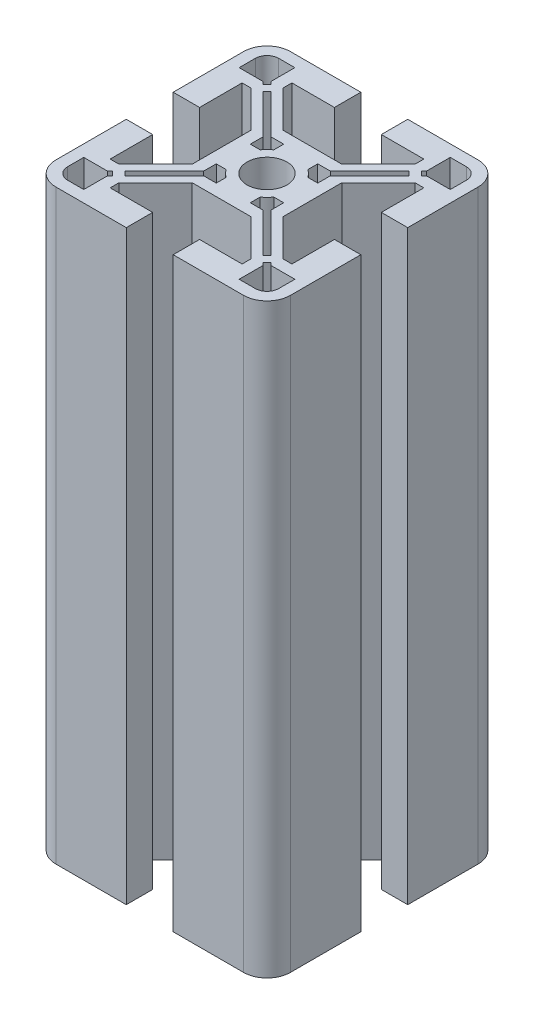
from build123d import *

# Parameters (mm, degrees)
BOSS_EXTRUDE1_DEPTH = 100


with BuildPart() as part:
    # Sketch1 → Boss-Extrude1 (new body)
    with BuildSketch(Plane(origin=(0, 0, 0), x_dir=(1, 0, 0), z_dir=(0, 1, 0))):
        with BuildLine():
            Line((-20, 4), (-20, 16))
            ThreePointArc((-20, 16), (-18.828427125, 18.828427125), (-16, 20))
            Line((-16, 20), (-4, 20))
            Line((-4, 20), (-4, 15.5))
            Line((-4, 15.5), (-11.25, 15.5))
            Line((-11.25, 15.5), (-11.25, 14))
            Line((-11.25, 14), (-5, 7.75))
            Line((-5, 7.75), (0, 7.75))
            Line((0, 7.75), (5, 7.75))
            Line((5, 7.75), (11.25, 14))
            Line((11.25, 14), (11.25, 15.5))
            Line((11.25, 15.5), (4, 15.5))
            Line((4, 15.5), (4, 20))
            Line((4, 20), (16, 20))
            ThreePointArc((16, 20), (18.828427125, 18.828427125), (20, 16))
            Line((20, 16), (20, 4))
            Line((20, 4), (15.5, 4))
            Line((15.5, 4), (15.5, 11.25))
            Line((15.5, 11.25), (14, 11.25))
            Line((14, 11.25), (7.75, 5))
            Line((7.75, 5), (7.75, 0))
            Line((7.75, 0), (7.75, -5))
            Line((7.75, -5), (14, -11.25))
            Line((14, -11.25), (15.5, -11.25))
            Line((15.5, -11.25), (15.5, -4))
            Line((15.5, -4), (20, -4))
            Line((20, -4), (20, -16))
            ThreePointArc((20, -16), (18.828427125, -18.828427125), (16, -20))
            Line((16, -20), (4, -20))
            Line((4, -20), (4, -15.5))
            Line((4, -15.5), (11.25, -15.5))
            Line((11.25, -15.5), (11.25, -14))
            Line((11.25, -14), (5, -7.75))
            Line((5, -7.75), (0, -7.75))
            Line((0, -7.75), (-5, -7.75))
            Line((-5, -7.75), (-11.25, -14))
            Line((-11.25, -14), (-11.25, -15.5))
            Line((-11.25, -15.5), (-4, -15.5))
            Line((-4, -15.5), (-4, -20))
            Line((-4, -20), (-16, -20))
            ThreePointArc((-16, -20), (-18.828427125, -18.828427125), (-20, -16))
            Line((-20, -16), (-20, -4))
            Line((-20, -4), (-15.5, -4))
            Line((-15.5, -4), (-15.5, -11.25))
            Line((-15.5, -11.25), (-14, -11.25))
            Line((-14, -11.25), (-7.75, -5))
            Line((-7.75, -5), (-7.75, 0))
            Line((-7.75, 0), (-7.75, 5))
            Line((-7.75, 5), (-14, 11.25))
            Line((-14, 11.25), (-15.5, 11.25))
            Line((-15.5, 11.25), (-15.5, 4))
            Line((-15.5, 4), (-20, 4))
        make_face()
        with BuildLine():
            Line((-18, 13.25), (-18, 16))
            ThreePointArc((-18, 16), (-17.414213562, 17.414213562), (-16, 18))
            Line((-16, 18), (-13.25, 18))
            Line((-13.25, 18), (-13.25, 13.957106781))
            Line((-13.25, 13.957106781), (-12.801776695, 13.508883476))
            Line((-12.801776695, 13.508883476), (-13.508883476, 12.801776695))
            Line((-13.508883476, 12.801776695), (-13.957106781, 13.25))
            Line((-13.957106781, 13.25), (-18, 13.25))
        make_face(mode=Mode.SUBTRACT)
        with BuildLine():
            Line((-12.448223305, 11.741116524), (-5.75, 5.042893219))
            Line((-5.75, 5.042893219), (-5.75, 2.90473751))
            Line((-5.75, 2.90473751), (-5.25, 2.90473751))
            Line((-5.25, 2.90473751), (-4.069705149, 2.90473751))
            ThreePointArc((-4.069705149, 2.90473751), (-3.535533906, 3.535533906), (-2.90473751, 4.069705149))
            Line((-2.90473751, 4.069705149), (-2.90473751, 5.25))
            Line((-2.90473751, 5.25), (-2.90473751, 5.75))
            Line((-2.90473751, 5.75), (-5.042893219, 5.75))
            Line((-5.042893219, 5.75), (-11.741116524, 12.448223305))
            Line((-11.741116524, 12.448223305), (-12.448223305, 11.741116524))
        make_face(mode=Mode.SUBTRACT)
        with BuildLine():
            Line((18, 13.25), (18, 16))
            ThreePointArc((18, 16), (17.414213562, 17.414213562), (16, 18))
            Line((16, 18), (13.25, 18))
            Line((13.25, 18), (13.25, 13.957106781))
            Line((13.25, 13.957106781), (12.801776695, 13.508883476))
            Line((12.801776695, 13.508883476), (13.508883476, 12.801776695))
            Line((13.508883476, 12.801776695), (13.957106781, 13.25))
            Line((13.957106781, 13.25), (18, 13.25))
        make_face(mode=Mode.SUBTRACT)
        with BuildLine():
            Line((5.75, 5.042893219), (5.75, 2.90473751))
            Line((5.75, 2.90473751), (5.25, 2.90473751))
            Line((5.25, 2.90473751), (4.069705149, 2.90473751))
            ThreePointArc((4.069705149, 2.90473751), (3.535533906, 3.535533906), (2.90473751, 4.069705149))
            Line((2.90473751, 4.069705149), (2.90473751, 5.25))
            Line((2.90473751, 5.25), (2.90473751, 5.75))
            Line((2.90473751, 5.75), (5.042893219, 5.75))
            Line((5.042893219, 5.75), (11.741116524, 12.448223305))
            Line((11.741116524, 12.448223305), (12.448223305, 11.741116524))
            Line((12.448223305, 11.741116524), (5.75, 5.042893219))
        make_face(mode=Mode.SUBTRACT)
        with BuildLine():
            Line((13.25, -18), (16, -18))
            ThreePointArc((16, -18), (17.414213562, -17.414213562), (18, -16))
            Line((18, -16), (18, -13.25))
            Line((18, -13.25), (13.957106781, -13.25))
            Line((13.957106781, -13.25), (13.508883476, -12.801776695))
            Line((13.508883476, -12.801776695), (12.801776695, -13.508883476))
            Line((12.801776695, -13.508883476), (13.25, -13.957106781))
            Line((13.25, -13.957106781), (13.25, -18))
        make_face(mode=Mode.SUBTRACT)
        with BuildLine():
            Line((5.042893219, -5.75), (2.90473751, -5.75))
            Line((2.90473751, -5.75), (2.90473751, -5.25))
            Line((2.90473751, -5.25), (2.90473751, -4.069705149))
            ThreePointArc((2.90473751, -4.069705149), (3.535533906, -3.535533906), (4.069705149, -2.90473751))
            Line((4.069705149, -2.90473751), (5.25, -2.90473751))
            Line((5.25, -2.90473751), (5.75, -2.90473751))
            Line((5.75, -2.90473751), (5.75, -5.042893219))
            Line((5.75, -5.042893219), (12.448223305, -11.741116524))
            Line((12.448223305, -11.741116524), (11.741116524, -12.448223305))
            Line((11.741116524, -12.448223305), (5.042893219, -5.75))
        make_face(mode=Mode.SUBTRACT)
        with BuildLine():
            Line((-18, -13.25), (-18, -16))
            ThreePointArc((-18, -16), (-17.414213562, -17.414213562), (-16, -18))
            Line((-16, -18), (-13.25, -18))
            Line((-13.25, -18), (-13.25, -13.957106781))
            Line((-13.25, -13.957106781), (-12.801776695, -13.508883476))
            Line((-12.801776695, -13.508883476), (-13.508883476, -12.801776695))
            Line((-13.508883476, -12.801776695), (-13.957106781, -13.25))
            Line((-13.957106781, -13.25), (-18, -13.25))
        make_face(mode=Mode.SUBTRACT)
        with BuildLine():
            Line((-5.75, -5.042893219), (-5.75, -2.90473751))
            Line((-5.75, -2.90473751), (-5.25, -2.90473751))
            Line((-5.25, -2.90473751), (-4.069705149, -2.90473751))
            ThreePointArc((-4.069705149, -2.90473751), (-3.535533906, -3.535533906), (-2.90473751, -4.069705149))
            Line((-2.90473751, -4.069705149), (-2.90473751, -5.25))
            Line((-2.90473751, -5.25), (-2.90473751, -5.75))
            Line((-2.90473751, -5.75), (-5.042893219, -5.75))
            Line((-5.042893219, -5.75), (-11.741116524, -12.448223305))
            Line((-11.741116524, -12.448223305), (-12.448223305, -11.741116524))
            Line((-12.448223305, -11.741116524), (-5.75, -5.042893219))
        make_face(mode=Mode.SUBTRACT)
        with BuildLine():
            ThreePointArc((-3.4, 0), (-2.404163056, 2.404163056), (0, 3.4))
            ThreePointArc((0, 3.4), (2.404163056, 2.404163056), (3.4, 0))
            ThreePointArc((3.4, 0), (2.404163056, -2.404163056), (0, -3.4))
            ThreePointArc((0, -3.4), (-2.404163056, -2.404163056), (-3.4, 0))
        make_face(mode=Mode.SUBTRACT)
    extrude(amount=BOSS_EXTRUDE1_DEPTH)


solid = part.part
